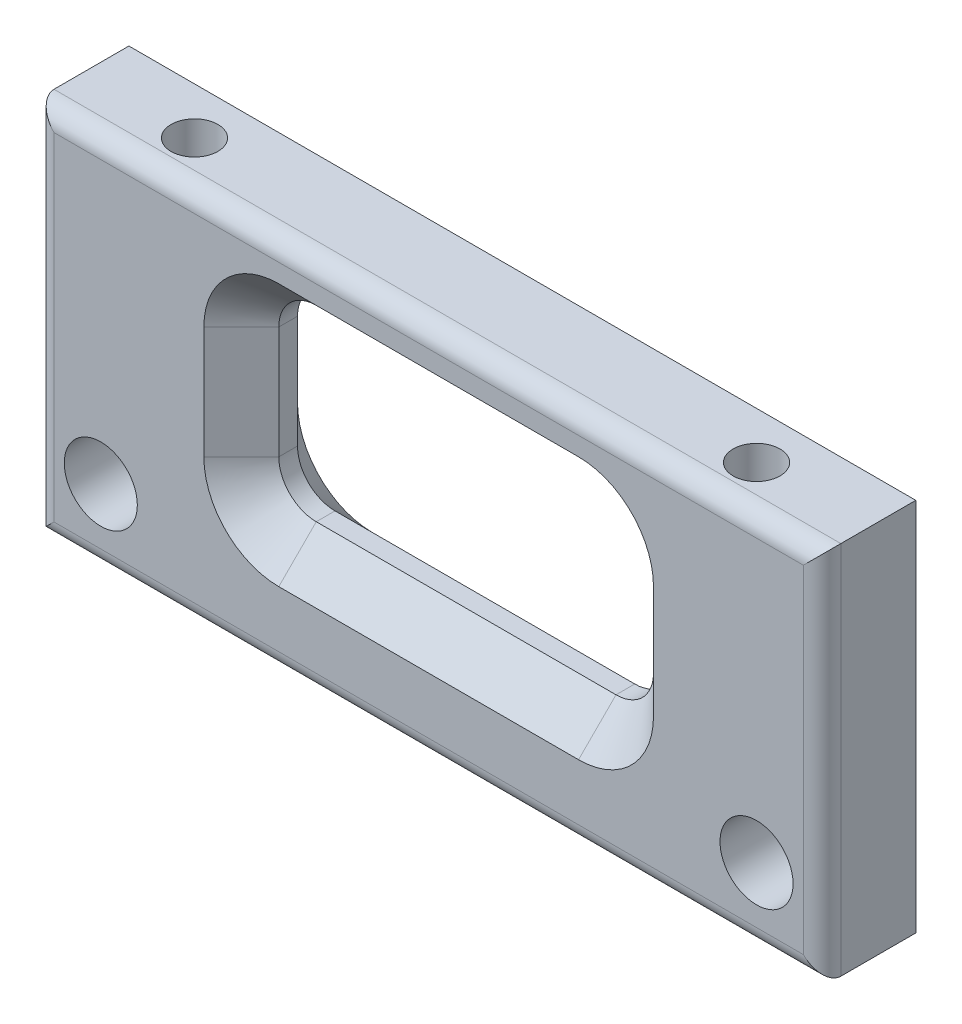
from build123d import *

# Parameters (mm, degrees)
SKETCH1_W           = 42
SKETCH1_H           = 20
SKETCH1_R           = 1.95
BOSS_EXTRUDE1_DEPTH = 5
SKETCH2_R           = 1.25
CUT_EXTRUDE1_DEPTH  = 10
CUT_EXTRUDE2_DEPTH  = 10
FILLET1_R           = 1
CHAMFER1_SIZE       = 2


with BuildPart() as part:
    # Sketch1 → Boss-Extrude1 (new body)
    with BuildSketch(Plane.XY):
        with Locations((21, -10)):
            Rectangle(SKETCH1_W, SKETCH1_H)
        with Locations((38.5, -16)):
            Circle(SKETCH1_R, mode=Mode.SUBTRACT)
        with Locations((3.5, -16)):
            Circle(SKETCH1_R, mode=Mode.SUBTRACT)
    extrude(amount=BOSS_EXTRUDE1_DEPTH)

    # Sketch2 → Cut-Extrude1 (cut)
    with BuildSketch(Plane(origin=(0, 0, 0), x_dir=(1, 0, 0), z_dir=(0, 1, 0))):
        with Locations((36, -2.5)):
            Circle(SKETCH2_R)
        with Locations((6, -2.5)):
            Circle(SKETCH2_R)
    extrude(amount=-CUT_EXTRUDE1_DEPTH, mode=Mode.SUBTRACT)

    # Sketch3 → Cut-Extrude2 (cut)
    with BuildSketch(Plane.XY.offset(5)):
        with BuildLine():
            Line((29, -13.990346174), (13, -13.990346174))
            ThreePointArc((13, -13.990346174), (11.585786438, -13.404559737), (11, -11.990346174))
            Line((11, -11.990346174), (11, -5.990346174))
            ThreePointArc((11, -5.990346174), (11.585786438, -4.576132612), (13, -3.990346174))
            Line((13, -3.990346174), (29, -3.990346174))
            ThreePointArc((29, -3.990346174), (30.414213562, -4.576132612), (31, -5.990346174))
            Line((31, -5.990346174), (31, -11.990346174))
            ThreePointArc((31, -11.990346174), (30.414213562, -13.404559737), (29, -13.990346174))
        make_face()
    extrude(amount=-CUT_EXTRUDE2_DEPTH, mode=Mode.SUBTRACT)

    # Fillet1
    fillet1_edges = [part.edges().sort_by_distance(p)[0] for p in [
        (42, -10, 5),
        (21, 0, 5),
        (0, -10, 5),
        (21, -20, 5),
    ]]
    fillet(fillet1_edges, radius=FILLET1_R)

    # Chamfer1
    chamfer1_edges = [part.edges().sort_by_distance(p)[0] for p in [
        (21, -13.990346174, 0),
        (30.414213562, -13.404559737, 0),
        (31, -8.990346174, 0),
        (30.414213562, -4.576132612, 0),
        (21, -3.990346174, 0),
        (11.585786438, -4.576132612, 0),
        (11, -8.990346174, 0),
        (11.585786438, -13.404559737, 0),
        (11.585786438, -13.404559737, 5),
        (21, -13.990346174, 5),
        (30.414213562, -13.404559737, 5),
        (31, -8.990346174, 5),
        (30.414213562, -4.576132612, 5),
        (21, -3.990346174, 5),
        (11.585786438, -4.576132612, 5),
        (11, -8.990346174, 5),
    ]]
    chamfer(chamfer1_edges, length=CHAMFER1_SIZE)


solid = part.part
